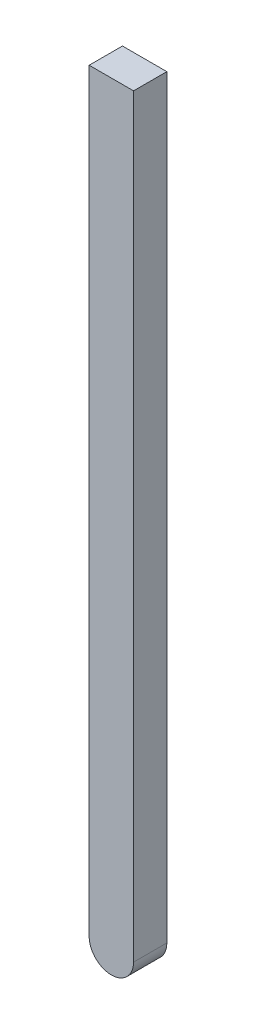
from build123d import *

# Parameters (mm, degrees)
DODANIE_WYCI_GNI_CIE1_DEPTH = 30


with BuildPart() as part:
    # Szkic1 → Dodanie-wyciągnięcie1 (new body)
    with BuildSketch(Plane.XY):
        with BuildLine():
            Line((0, 0), (40, 0))
            Line((40, 0), (40, -680))
            ThreePointArc((40, -680), (20, -700), (0, -680))
            Line((0, -680), (0, 0))
        make_face()
    extrude(amount=DODANIE_WYCI_GNI_CIE1_DEPTH)


solid = part.part
